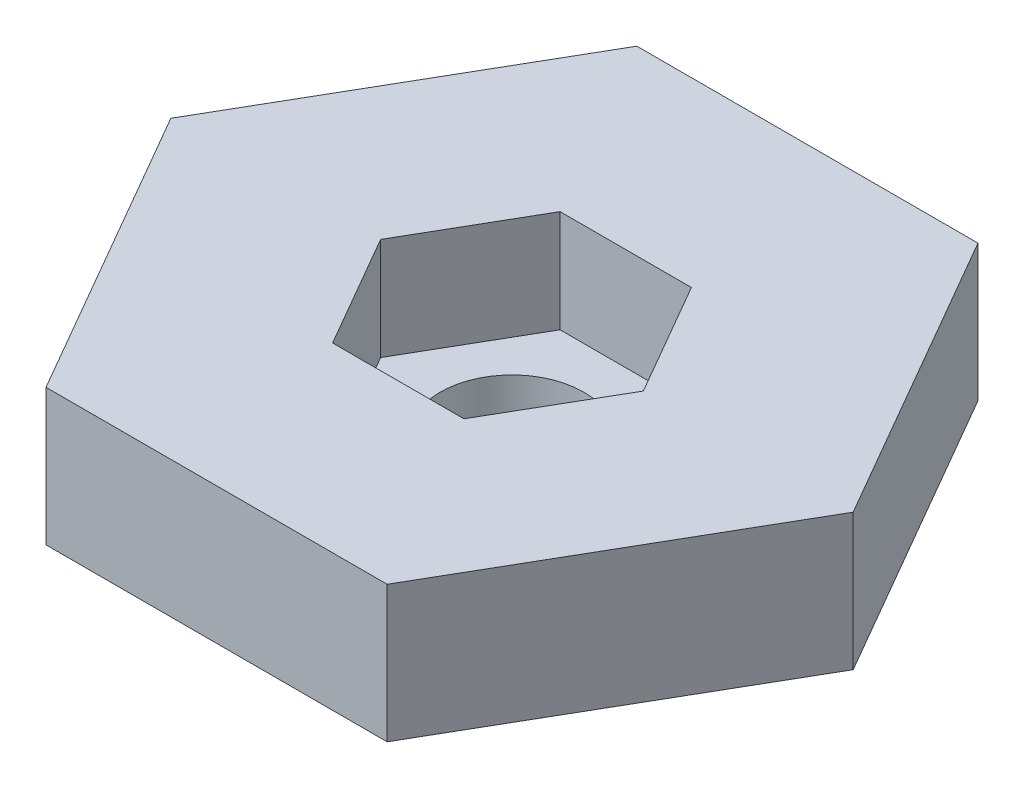
from build123d import *

# Parameters (mm, degrees)
BOSS_EXTRUDE1_DEPTH = 6
SKETCH2_R           = 4.2
BOSS_EXTRUDE2_DEPTH = 2


with BuildPart() as part:
    # Sketch1 → Boss-Extrude1 (new body)
    with BuildSketch(Plane(origin=(0, 0, 0), x_dir=(1, 0, 0), z_dir=(0, 1, 0))):
        Polygon((-10, 17.320508076), (-20, 0), (-10, -17.320508076), (10, -17.320508076), (20, 0), (10, 17.320508076), align=None)
        Polygon((-3.85, 6.668395609), (-7.7, 0), (-3.85, -6.668395609), (3.85, -6.668395609), (7.7, 0), (3.85, 6.668395609), align=None, mode=Mode.SUBTRACT)
    extrude(amount=BOSS_EXTRUDE1_DEPTH)

    # Sketch2 → Boss-Extrude2 (add)
    with BuildSketch(Plane.XZ):
        Polygon((20, 0), (10, -17.320508076), (-10, -17.320508076), (-20, 0), (-10, 17.320508076), (10, 17.320508076), align=None)
        Circle(SKETCH2_R, mode=Mode.SUBTRACT)
    extrude(amount=BOSS_EXTRUDE2_DEPTH)


solid = part.part
